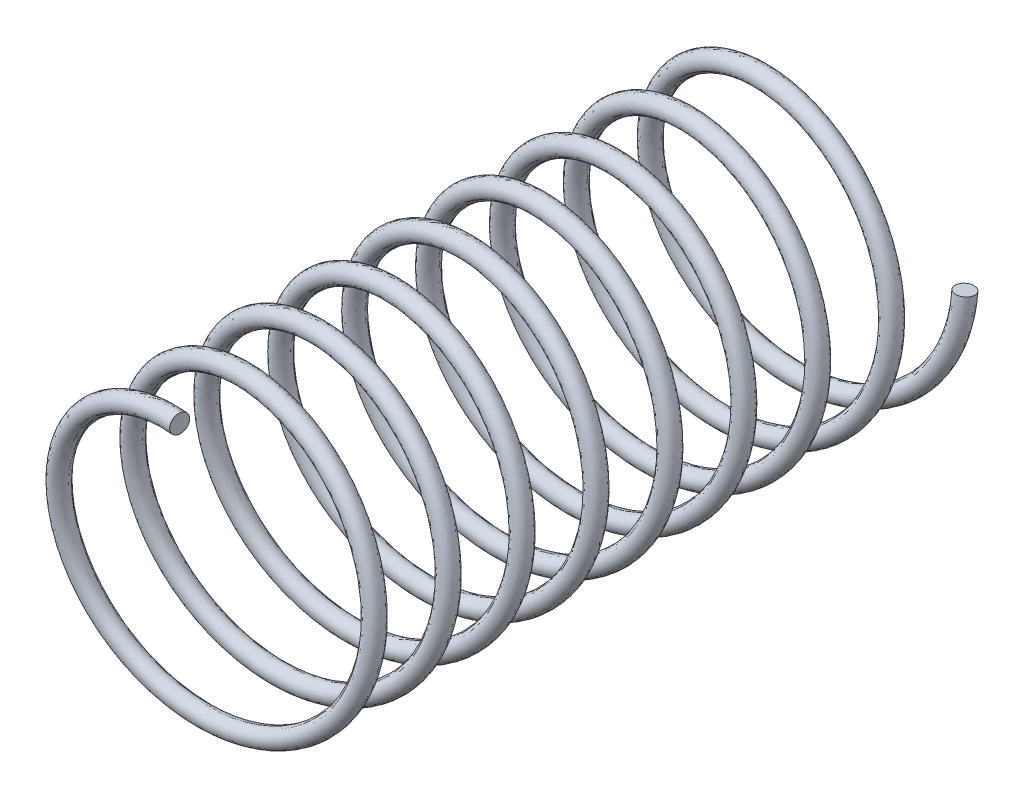
from build123d import *

# Parameters (mm, degrees)
SWEEP1_PITCH     = 80
SWEEP1_HEIGHT    = 700
SWEEP1_RADIUS    = 150
SWEEP1_PROFILE_R = 10


with BuildPart() as part:
    # Sweep1: sweep along a helix
    with BuildLine() as sweep1_path:
        Helix(SWEEP1_PITCH, SWEEP1_HEIGHT, SWEEP1_RADIUS, center=(0, 0, 0), direction=(0, 0, 1), lefthand=True)
    # Sweep1 profile (on start of the path) → Sweep1 (sweep)
    with BuildSketch(Plane(origin=(150, 0, 0), x_dir=(0, -0.084578487, -0.99641682), z_dir=(0, -0.99641682, 0.084578487))):
        Circle(SWEEP1_PROFILE_R)
    sweep(path=sweep1_path.line, is_frenet=True)


solid = part.part
